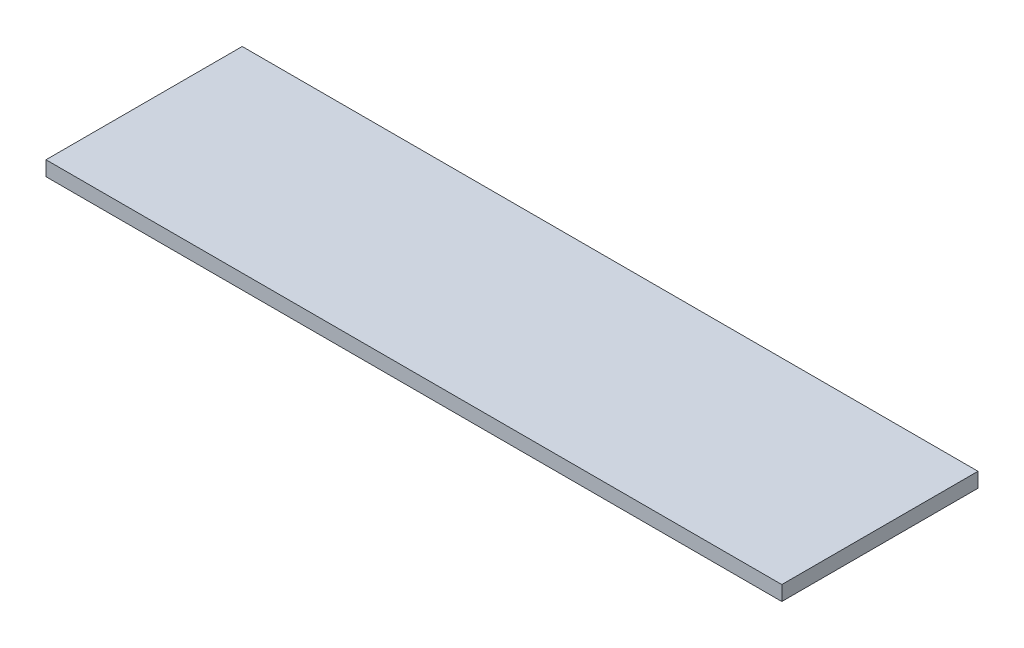
from build123d import *

# Parameters (mm, degrees)
ESQUISSE1_W        = 300
ESQUISSE1_H        = 6
BOSS_EXTRU_1_DEPTH = 80


with BuildPart() as part:
    # Esquisse1 → Boss.-Extru.1 (new body)
    with BuildSketch(Plane.XY):
        Rectangle(ESQUISSE1_W, ESQUISSE1_H)
    extrude(amount=BOSS_EXTRU_1_DEPTH)


solid = part.part
